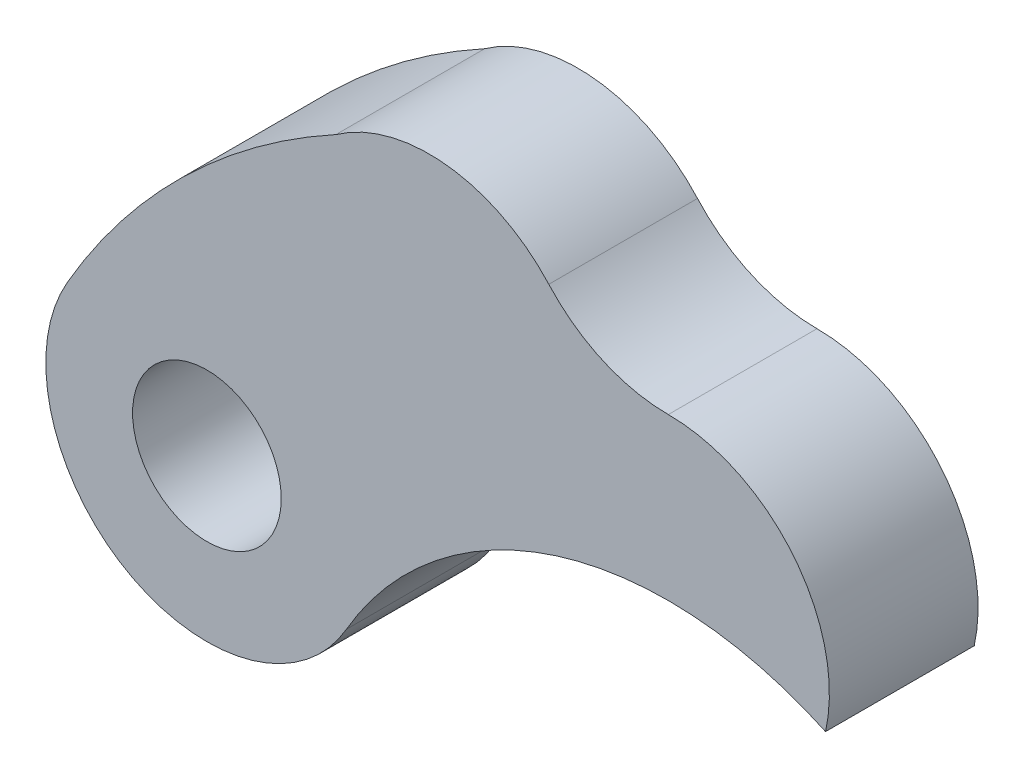
from build123d import *

# Parameters (mm, degrees)
ESQUISSE1_R        = 1.5
BOSS_EXTRU_2_DEPTH = 3


with BuildPart() as part:
    # Esquisse1 → Boss.-Extru.2 (new body)
    with BuildSketch(Plane.XY):
        with BuildLine():
            ThreePointArc((-2.411034891, 11.820685714), (-1.319039152, 11.029707807), (0, 10.75))
            ThreePointArc((0, 10.75), (2.534861107, 9.53395653), (3.17279834, 6.795833333))
            ThreePointArc((3.17279834, 6.795833333), (-2.25362988, 7.153401454), (-6.495190528, 3.75))
            ThreePointArc((-6.495190528, 3.75), (-10.934773091, 2.560417438), (-12.124355653, 7))
            ThreePointArc((-12.124355653, 7), (-9.780131311, 10.017436376), (-6.707371512, 12.288660114))
            ThreePointArc((-6.707371512, 12.288660114), (-4.47014813, 12.872261577), (-2.411034891, 11.820685714))
        make_face()
        with Locations((-9.309773091, 5.375)):
            Circle(ESQUISSE1_R, mode=Mode.SUBTRACT)
    extrude(amount=BOSS_EXTRU_2_DEPTH)


solid = part.part
